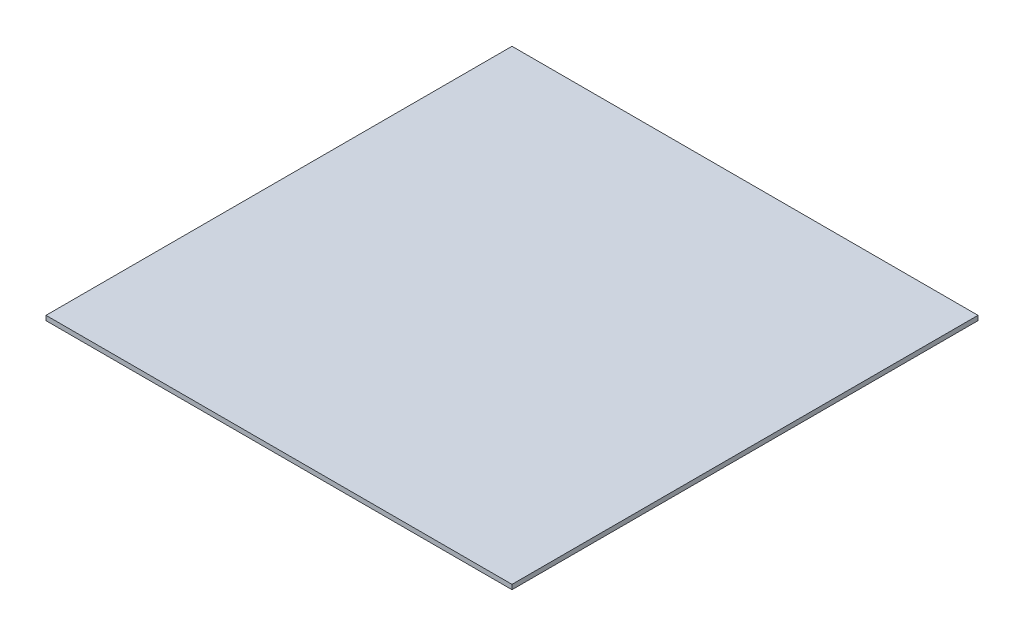
from build123d import *

# Parameters (mm, degrees)
SKETCH1_W           = 2540
SKETCH1_H           = 2540
BOSS_EXTRUDE1_DEPTH = 25.4


with BuildPart() as part:
    # Sketch1 → Boss-Extrude1 (new body)
    with BuildSketch(Plane(origin=(0, 0, 0), x_dir=(1, 0, 0), z_dir=(0, 1, 0))):
        Rectangle(SKETCH1_W, SKETCH1_H)
    extrude(amount=BOSS_EXTRUDE1_DEPTH)


solid = part.part
